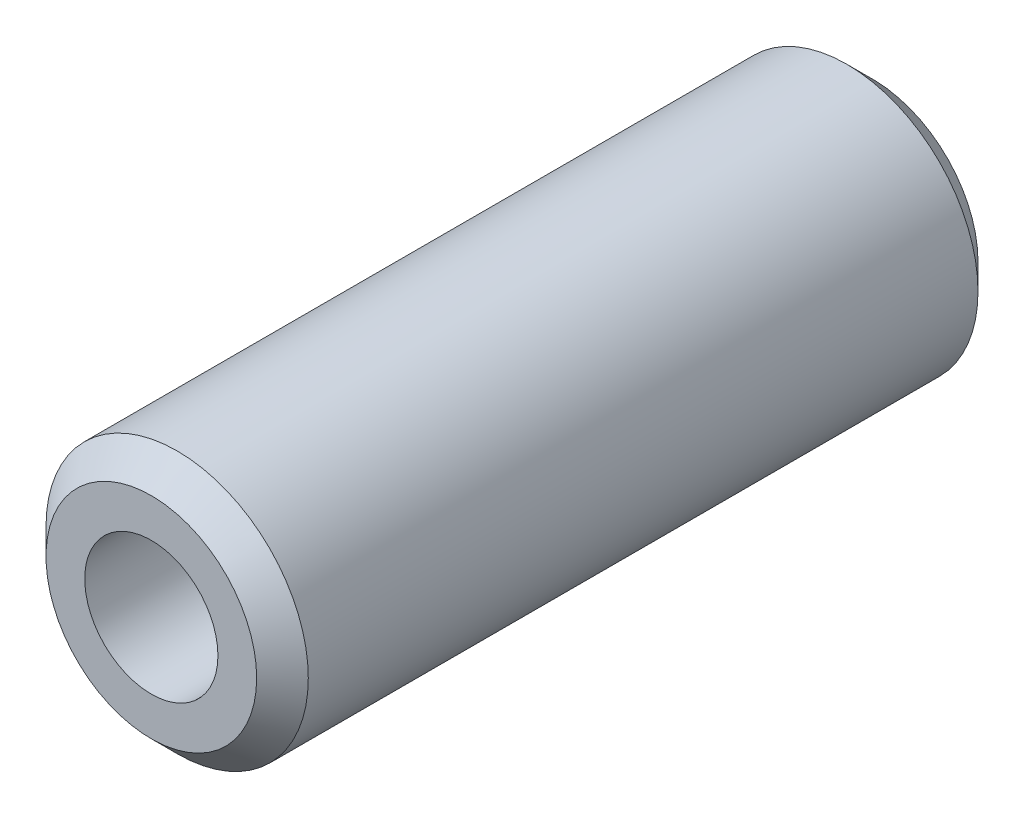
from build123d import *

# Parameters (mm, degrees)
SKETCH2_R           = 12.7
BOSS_EXTRUDE1_DEPTH = 69.85
SKETCH3_R           = 6.45
CUT_EXTRUDE1_DEPTH  = 70.85
CHAMFER1_SIZE       = 2.5


with BuildPart() as part:
    # Sketch2 → Boss-Extrude1 (new body)
    with BuildSketch(Plane.XY):
        Circle(SKETCH2_R)
    extrude(amount=BOSS_EXTRUDE1_DEPTH)

    # Sketch3 → Cut-Extrude1 (cut, through all)
    with BuildSketch(Plane.XY.offset(69.85)):
        Circle(SKETCH3_R)
    extrude(amount=-CUT_EXTRUDE1_DEPTH, mode=Mode.SUBTRACT)

    # Chamfer1
    chamfer1_edges = [part.edges().sort_by_distance(p)[0] for p in [
        (-12.7, 0, 0),
        (-12.7, 0, 69.85),
    ]]
    chamfer(chamfer1_edges, length=CHAMFER1_SIZE)


solid = part.part
